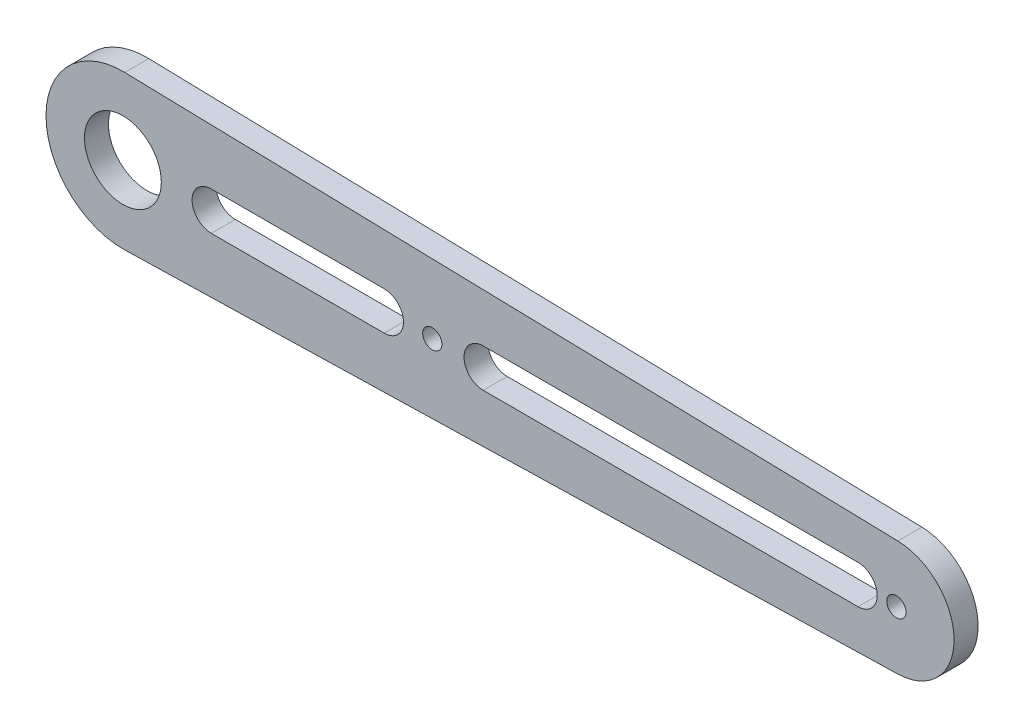
from build123d import *

# Parameters (mm, degrees)
SKETCH_1_R      = 8
SKETCH_1_R_2    = 2
EXTRUDE_1_DEPTH = 5


with BuildPart() as part:
    # 草图1 → 凸台-拉伸1 (new body)
    with BuildSketch(Plane.XY):
        with BuildLine():
            Line((0.397515528, -15.995061157), (161.298136646, -11.996295867))
            ThreePointArc((161.298136646, -11.996295867), (173, 0), (161.298136646, 11.996295867))
            Line((161.298136646, 11.996295867), (0.397515528, 15.995061157))
            ThreePointArc((0.397515528, 15.995061157), (-16, 0), (0.397515528, -15.995061157))
        make_face()
        Circle(SKETCH_1_R, mode=Mode.SUBTRACT)
        with Locations((161, 0)):
            Circle(SKETCH_1_R_2, mode=Mode.SUBTRACT)
        with Locations((64.4, 0)):
            Circle(SKETCH_1_R_2, mode=Mode.SUBTRACT)
        with BuildLine():
            Line((18.4, 4), (54.4, 4))
            ThreePointArc((54.4, 4), (58.4, 0), (54.4, -4))
            Line((54.4, -4), (18.4, -4))
            ThreePointArc((18.4, -4), (14.4, 0), (18.4, 4))
        make_face(mode=Mode.SUBTRACT)
        with BuildLine():
            Line((75, 4), (153, 4))
            ThreePointArc((153, 4), (157, 0), (153, -4))
            Line((153, -4), (75, -4))
            ThreePointArc((75, -4), (71, 0), (75, 4))
        make_face(mode=Mode.SUBTRACT)
    extrude(amount=EXTRUDE_1_DEPTH)


solid = part.part
